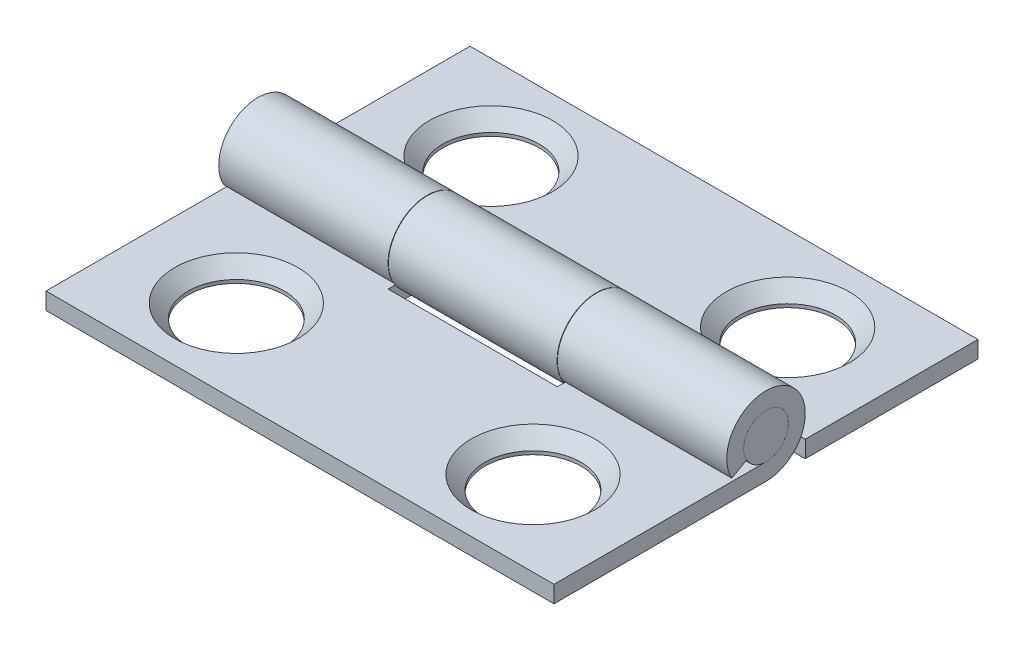
from build123d import *

# Parameters (mm, degrees)
BOSS_EXTRUDE1_DEPTH     = 9.525
CIRPATTERN1_COUNT       = 2
SKETCH4_W               = 6.35
SKETCH4_H               = 2.9464
CUT_EXTRUDE1_DEPTH      = 2.4732
CUT_EXTRUDE1_DEPTH_BACK = 2.4732
SKETCH10_W              = 6.3627
SKETCH10_H              = 2.9464
CUT_EXTRUDE4_DEPTH      = 2.4732
CUT_EXTRUDE4_DEPTH_BACK = 2.4732
SKETCH5_R               = 2.3114
CUT_EXTRUDE2_DEPTH      = 1.635
CUT_EXTRUDE2_TAPER      = 45
SKETCH9_R               = 1.8034
CUT_EXTRUDE3_DEPTH      = 2.4732
CUT_EXTRUDE3_DEPTH_BACK = 2.4732001
SKETCH11_R              = 2.3114
CUT_EXTRUDE5_DEPTH      = 1.635
CUT_EXTRUDE5_TAPER      = 45
SKETCH12_R              = 1.8034
CUT_EXTRUDE6_DEPTH      = 3.3114
CUT_EXTRUDE6_DEPTH_BACK = 1.6350001
SKETCH6_R               = 0.8382
BOSS_EXTRUDE2_DEPTH     = 9.525


with BuildPart() as part:
    # Sketch3 → Boss-Extrude1 (new body, symmetric)
    with BuildSketch(Plane(origin=(0, 0, 0), x_dir=(0, 0, -1), z_dir=(1, 0, 0))):
        with BuildLine():
            Line((0, -1.4732), (-7.9502, -1.4732))
            Line((-7.9502, -1.4732), (-7.9502, -0.8382))
            Line((-7.9502, -0.8382), (0, -0.8382))
            ThreePointArc((0, -0.8382), (0.421388638, 0.724576328), (-0.728533124, -0.414510226))
            Line((-0.728533124, -0.414510226), (-1.280452157, -0.728533124))
            ThreePointArc((-1.280452157, -0.728533124), (0.740622455, 1.273497789), (0, -1.4732))
        make_face()
    extrude(amount=BOSS_EXTRUDE1_DEPTH, both=True)


with BuildPart() as cirpattern1_1:
    # CirPattern1: pattern copy
    add(part.part.rotate(Axis((0, 0, 0), (0, 1, 0)), 1 * 360 / CIRPATTERN1_COUNT))

    # Sketch10 → Cut-Extrude4 (cut, two sides)
    with BuildSketch(Plane(origin=(0, 0, 0), x_dir=(1, 0, 0), z_dir=(0, 1, 0))) as cut_extrude4_sk:
        with Locations((-6.34365, 0)):
            Rectangle(SKETCH10_W, SKETCH10_H)
        with Locations((6.34365, 0)):
            Rectangle(SKETCH10_W, SKETCH10_H)
    extrude(amount=CUT_EXTRUDE4_DEPTH, mode=Mode.SUBTRACT)
    extrude(cut_extrude4_sk.sketch, amount=-CUT_EXTRUDE4_DEPTH_BACK, mode=Mode.SUBTRACT)

    # Sketch11 → Cut-Extrude5 (cut, through all)
    with BuildSketch(Plane(origin=(0, -0.8382, 0), x_dir=(1, 0, 0), z_dir=(0, 1, 0))):
        with Locations((5.5626, 4.7752)):
            Circle(SKETCH11_R)
        with Locations((-5.5626, 4.7752)):
            Circle(SKETCH11_R)
    extrude(amount=-CUT_EXTRUDE5_DEPTH, taper=CUT_EXTRUDE5_TAPER, mode=Mode.SUBTRACT)

    # Sketch12 → Cut-Extrude6 (cut, two sides)
    with BuildSketch(Plane(origin=(0, -0.8382, 0), x_dir=(1, 0, 0), z_dir=(0, 1, 0))) as cut_extrude6_sk:
        with Locations((-5.5626, 4.7752)):
            Circle(SKETCH12_R)
        with Locations((5.5626, 4.7752)):
            Circle(SKETCH12_R)
    extrude(amount=CUT_EXTRUDE6_DEPTH, mode=Mode.SUBTRACT)
    extrude(cut_extrude6_sk.sketch, amount=-CUT_EXTRUDE6_DEPTH_BACK, mode=Mode.SUBTRACT)


with BuildPart() as part_1:
    add(part.part)

    # Sketch4 → Cut-Extrude1 (cut, two sides)
    with BuildSketch(Plane(origin=(0, 0, 0), x_dir=(1, 0, 0), z_dir=(0, 1, 0))) as cut_extrude1_sk:
        Rectangle(SKETCH4_W, SKETCH4_H)
    extrude(amount=CUT_EXTRUDE1_DEPTH, mode=Mode.SUBTRACT)
    extrude(cut_extrude1_sk.sketch, amount=-CUT_EXTRUDE1_DEPTH_BACK, mode=Mode.SUBTRACT)

    # Sketch5 → Cut-Extrude2 (cut, through all)
    with BuildSketch(Plane(origin=(0, -0.8382, 0), x_dir=(1, 0, 0), z_dir=(0, 1, 0))):
        with Locations((5.5626, -4.7752)):
            Circle(SKETCH5_R)
        with Locations((-5.5626, -4.7752)):
            Circle(SKETCH5_R)
    extrude(amount=-CUT_EXTRUDE2_DEPTH, taper=CUT_EXTRUDE2_TAPER, mode=Mode.SUBTRACT)

    # Sketch9 → Cut-Extrude3 (cut, two sides)
    with BuildSketch(Plane(origin=(0, 0, 0), x_dir=(1, 0, 0), z_dir=(0, 1, 0))) as cut_extrude3_sk:
        with Locations((5.5626, -4.7752)):
            Circle(SKETCH9_R)
        with Locations((-5.5626, -4.7752)):
            Circle(SKETCH9_R)
    extrude(amount=CUT_EXTRUDE3_DEPTH, mode=Mode.SUBTRACT)
    extrude(cut_extrude3_sk.sketch, amount=-CUT_EXTRUDE3_DEPTH_BACK, mode=Mode.SUBTRACT)


with BuildPart() as body_3:
    # Sketch6 → Boss-Extrude2 (new body, symmetric)
    with BuildSketch(Plane(origin=(0, 0, 0), x_dir=(0, 0, -1), z_dir=(1, 0, 0))):
        Circle(SKETCH6_R)
    extrude(amount=BOSS_EXTRUDE2_DEPTH, both=True)


solid = Compound([cirpattern1_1.part, part_1.part, body_3.part])
